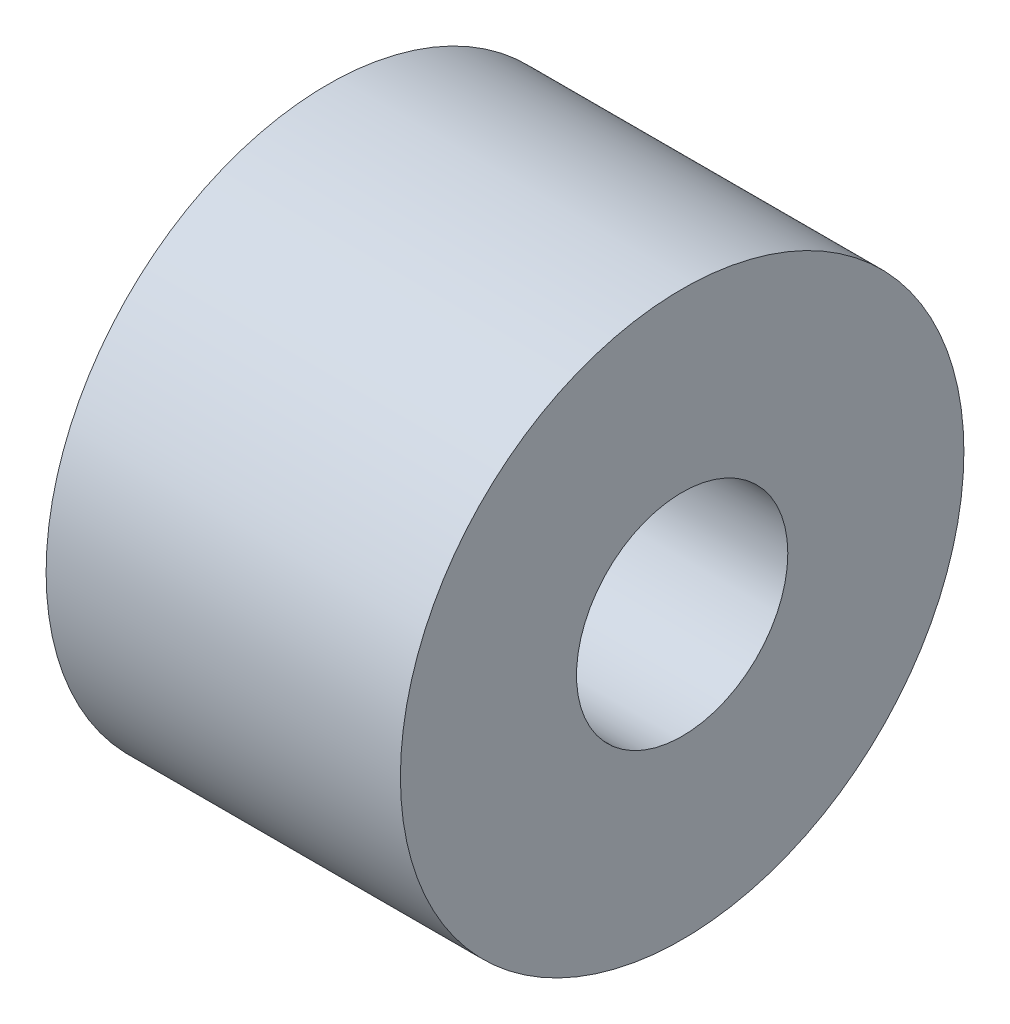
from build123d import *

# Parameters (mm, degrees)
SKETCH1_R      = 4
EXTRUDE1_DEPTH = 2.515
SKETCH2_R      = 1.5
EXTRUDE2_DEPTH = 6.03


with BuildPart() as part:
    # Sketch1 → Extrude1 (new body, symmetric)
    with BuildSketch(Plane(origin=(0, 0, 0), x_dir=(0, 0, -1), z_dir=(1, 0, 0))):
        Circle(SKETCH1_R)
    extrude(amount=EXTRUDE1_DEPTH, both=True)

    # Sketch2 → Extrude2 (cut, through all)
    with BuildSketch(Plane(origin=(2.515, 0, 0), x_dir=(0, 0, -1), z_dir=(1, 0, 0))):
        Circle(SKETCH2_R)
    extrude(amount=-EXTRUDE2_DEPTH, mode=Mode.SUBTRACT)


solid = part.part
